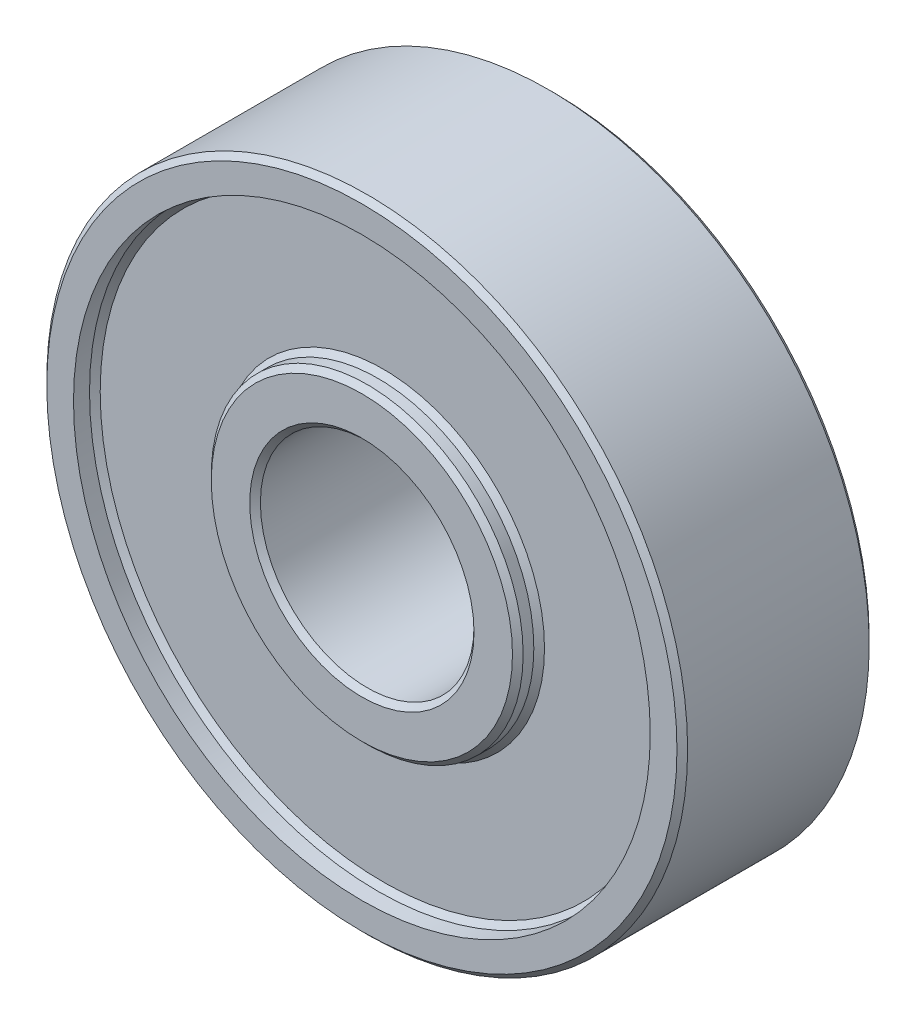
from build123d import *

# Parameters (mm, degrees)
SKETCH_1_R          = 15
EXTRUDE_1_DEPTH     = 9
SKETCH_2_R          = 5
CUT_EXTRUDE_1_DEPTH = 10
SKETCH_3_W          = 6.2
SKETCH_3_H          = 1
CHAMFER_1_SIZE      = 0.25


with BuildPart() as part:
    # Эскиз1 → Бобышка-Вытянуть1 (new body)
    with BuildSketch(Plane.XY):
        Circle(SKETCH_1_R)
    extrude(amount=EXTRUDE_1_DEPTH)

    # Эскиз2 → Вырез-Вытянуть1 (cut, through all)
    with BuildSketch(Plane(origin=(0, 0, 0), x_dir=(-1, 0, 0), z_dir=(0, 0, -1))):
        Circle(SKETCH_2_R)
    extrude(amount=-CUT_EXTRUDE_1_DEPTH, mode=Mode.SUBTRACT)

    # Эскиз3 → Вырез-Повернуть1 (revolve, cut)
    with BuildSketch(Plane(origin=(0, 0, 0), x_dir=(1, 0, 0), z_dir=(0, 1, 0))):
        with Locations((10.4, -8.5)):
            Rectangle(SKETCH_3_W, SKETCH_3_H)
        with Locations((10.4, -0.5)):
            Rectangle(SKETCH_3_W, SKETCH_3_H)
    revolve(axis=Axis((0, 0, 9), (0, 0, -1)), mode=Mode.SUBTRACT)

    # Фаска1
    chamfer_1_edges = [part.edges().sort_by_distance(p)[0] for p in [
        (-7.3, 0, 9),
        (-7.3, 0, 8),
        (-13.5, 0, 8),
        (-7.3, 0, 1),
        (-13.5, 0, 1),
        (-7.3, 0, 0),
        (-15, 0, 0),
        (-15, 0, 9),
        (5, 0, 9),
        (5, 0, 0),
    ]]
    chamfer(chamfer_1_edges, length=CHAMFER_1_SIZE)


solid = part.part
